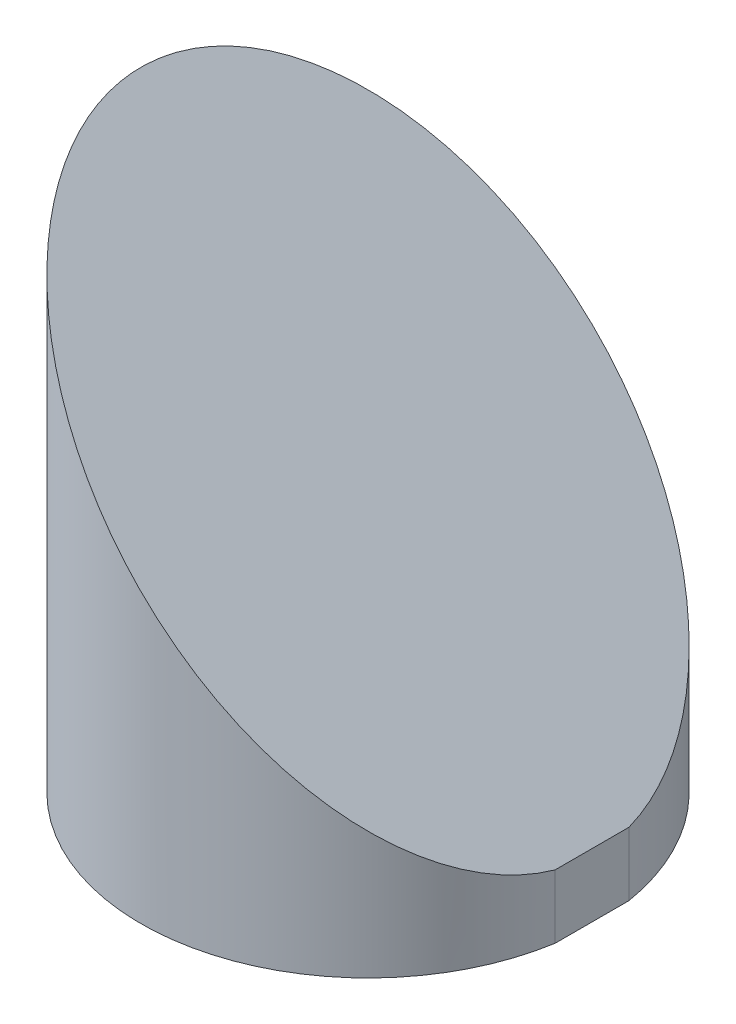
from build123d import *

# Parameters (mm, degrees)
SKETCH1_R               = 9.525
EXTRUDE1_DEPTH          = 21.59
CUT_EXTRUDE1_DEPTH      = 10.525
CUT_EXTRUDE1_DEPTH_BACK = 10.525
CUT_EXTRUDE2_DEPTH      = 22.59


with BuildPart() as part:
    # Sketch1 → Extrude1 (new body)
    with BuildSketch(Plane(origin=(0, 0, 0), x_dir=(1, 0, 0), z_dir=(0, 1, 0))):
        with Locations(Location((0, 0, 0), (0, 0, 270))):  # turned: the seam where the file's is
            Circle(SKETCH1_R)
    extrude(amount=EXTRUDE1_DEPTH)

    # Sketch2 → Cut-Extrude1 (cut, two sides)
    with BuildSketch(Plane.XY) as cut_extrude1_sk:
        Polygon((-9.525, 21.59), (9.525, 2.54), (9.525, 21.59), align=None)
    extrude(amount=CUT_EXTRUDE1_DEPTH, mode=Mode.SUBTRACT)
    extrude(cut_extrude1_sk.sketch, amount=-CUT_EXTRUDE1_DEPTH_BACK, mode=Mode.SUBTRACT)

    # Sketch3 → Cut-Extrude2 (cut, through all)
    with BuildSketch(Plane.XZ):
        with BuildLine():
            Line((9.398, 1.550232563), (9.398, -1.550232563))
            ThreePointArc((9.398, -1.550232563), (9.525, 0), (9.398, 1.550232563))
        make_face()
    extrude(amount=-CUT_EXTRUDE2_DEPTH, mode=Mode.SUBTRACT)


solid = part.part
